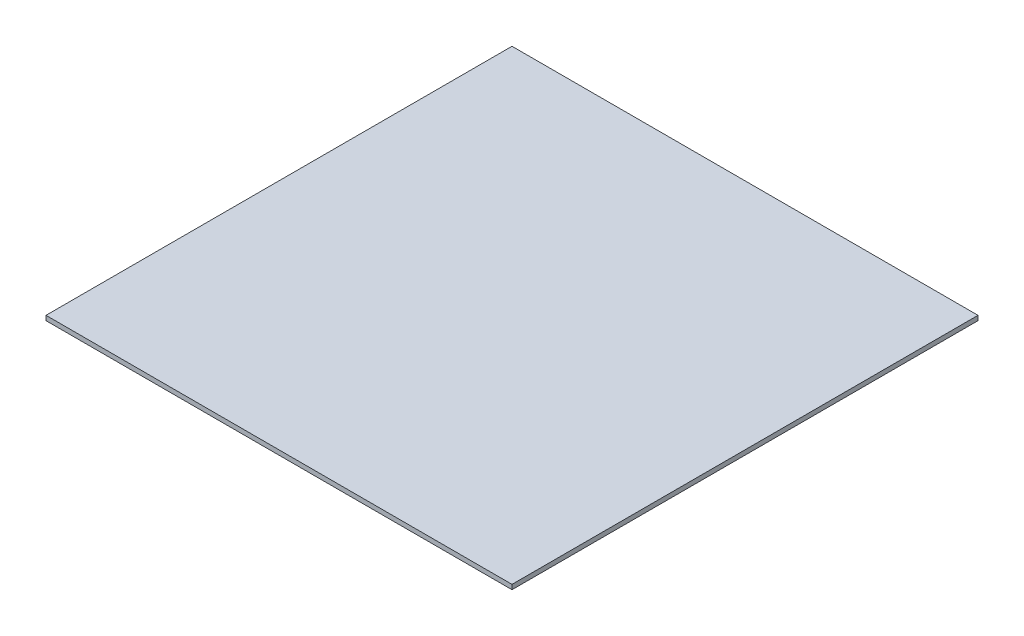
from build123d import *

# Parameters (mm, degrees)
SKETCH1_W           = 500
SKETCH1_H           = 500
BOSS_EXTRUDE1_DEPTH = 5


with BuildPart() as part:
    # Sketch1 → Boss-Extrude1 (new body)
    with BuildSketch(Plane(origin=(0, 0, 0), x_dir=(1, 0, 0), z_dir=(0, 1, 0))):
        Rectangle(SKETCH1_W, SKETCH1_H)
    extrude(amount=-BOSS_EXTRUDE1_DEPTH)


solid = part.part
